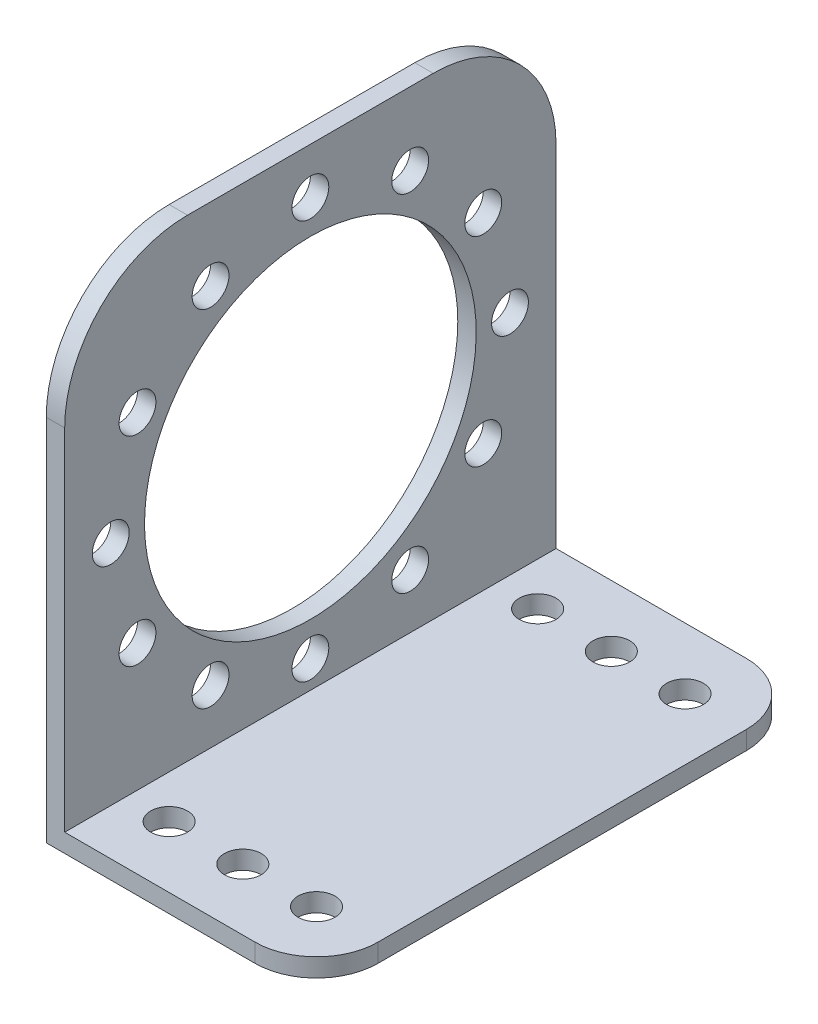
from build123d import *

# Parameters (mm, degrees)
BOSS_EXTRUDE1_DEPTH = 20
SKETCH2_R           = 13.5
CUT_EXTRUDE1_DEPTH  = 40
SKETCH4_R           = 1.5
CUT_EXTRUDE2_DEPTH  = 40
SKETCH5_R           = 1.5
CUT_EXTRUDE3_DEPTH  = 40
FILLET1_R           = 10
FILLET2_R           = 5


with BuildPart() as part:
    # Sketch1 → Boss-Extrude1 (new body, symmetric)
    with BuildSketch(Plane.XY):
        Polygon((0, 0), (22, 0), (22, 1.5), (1.5, 1.5), (1.5, 40), (0, 40), align=None)
    extrude(amount=BOSS_EXTRUDE1_DEPTH, both=True)

    # Sketch2 → Cut-Extrude1 (cut)
    with BuildSketch(Plane(origin=(1.5, 0, 0), x_dir=(0, 0, -1), z_dir=(1, 0, 0))):
        with Locations((0, 20)):
            Circle(SKETCH2_R)
    extrude(amount=-CUT_EXTRUDE1_DEPTH, mode=Mode.SUBTRACT)

    # Sketch4 → Cut-Extrude2 (cut)
    with BuildSketch(Plane(origin=(1.5, 0, 0), x_dir=(0, 0, -1), z_dir=(1, 0, 0))):
        with Locations((16.25, 20)):
            Circle(SKETCH4_R)
        with Locations((14.072912811, 11.875)):
            Circle(SKETCH4_R)
        with Locations((8.125, 5.927087189)):
            Circle(SKETCH4_R)
        with Locations((0, 3.75)):
            Circle(SKETCH4_R)
        with Locations((-8.125, 5.927087189)):
            Circle(SKETCH4_R)
        with Locations((-14.072912811, 11.875)):
            Circle(SKETCH4_R)
        with Locations((-16.25, 20)):
            Circle(SKETCH4_R)
        with Locations((-14.072912811, 28.125)):
            Circle(SKETCH4_R)
        with Locations((-8.125, 34.072912811)):
            Circle(SKETCH4_R)
        with Locations((0, 36.25)):
            Circle(SKETCH4_R)
        with Locations((8.125, 34.072912811)):
            Circle(SKETCH4_R)
        with Locations((14.072912811, 28.125)):
            Circle(SKETCH4_R)
    extrude(amount=-CUT_EXTRUDE2_DEPTH, mode=Mode.SUBTRACT)

    # Sketch5 → Cut-Extrude3 (cut)
    with BuildSketch(Plane(origin=(0, 1.5, 0), x_dir=(1, 0, 0), z_dir=(0, 1, 0))):
        with Locations((5, 15)):
            Circle(SKETCH5_R)
        with Locations((11, 15)):
            Circle(SKETCH5_R)
        with Locations((17, 15)):
            Circle(SKETCH5_R)
        with Locations((17, -15)):
            Circle(SKETCH5_R)
        with Locations((11, -15)):
            Circle(SKETCH5_R)
        with Locations((5, -15)):
            Circle(SKETCH5_R)
    extrude(amount=-CUT_EXTRUDE3_DEPTH, mode=Mode.SUBTRACT)

    # Fillet1
    fillet1_edges = [part.edges().sort_by_distance(p)[0] for p in [
        (0.75, 40, 20),
        (0.75, 40, -20),
    ]]
    fillet(fillet1_edges, radius=FILLET1_R)

    # Fillet2
    fillet2_edges = [part.edges().sort_by_distance(p)[0] for p in [
        (22, 0.75, 20),
        (22, 0.75, -20),
    ]]
    fillet(fillet2_edges, radius=FILLET2_R)


solid = part.part
